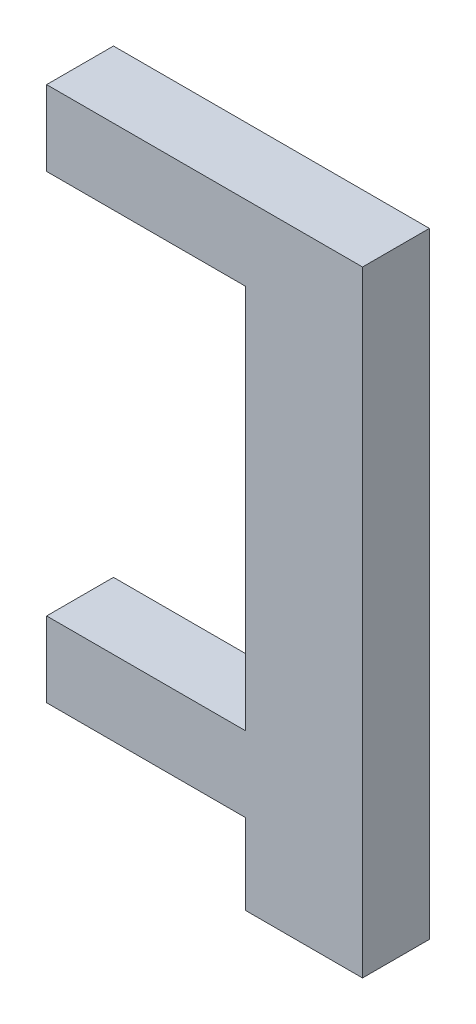
from build123d import *

# Parameters (mm, degrees)
BOSS_EXTRUDE1_DEPTH = 4


with BuildPart() as part:
    # Sketch5 → Boss-Extrude1 (new body)
    with BuildSketch(Plane.XY):
        Polygon((0, 0), (0, 36.84), (-18.9, 36.84), (-18.9, 32.34), (-7, 32.34), (-7, 9.31), (-18.9, 9.31), (-18.9, 4.81), (-7, 4.81), (-7, 0), align=None)
    extrude(amount=BOSS_EXTRUDE1_DEPTH)


solid = part.part
